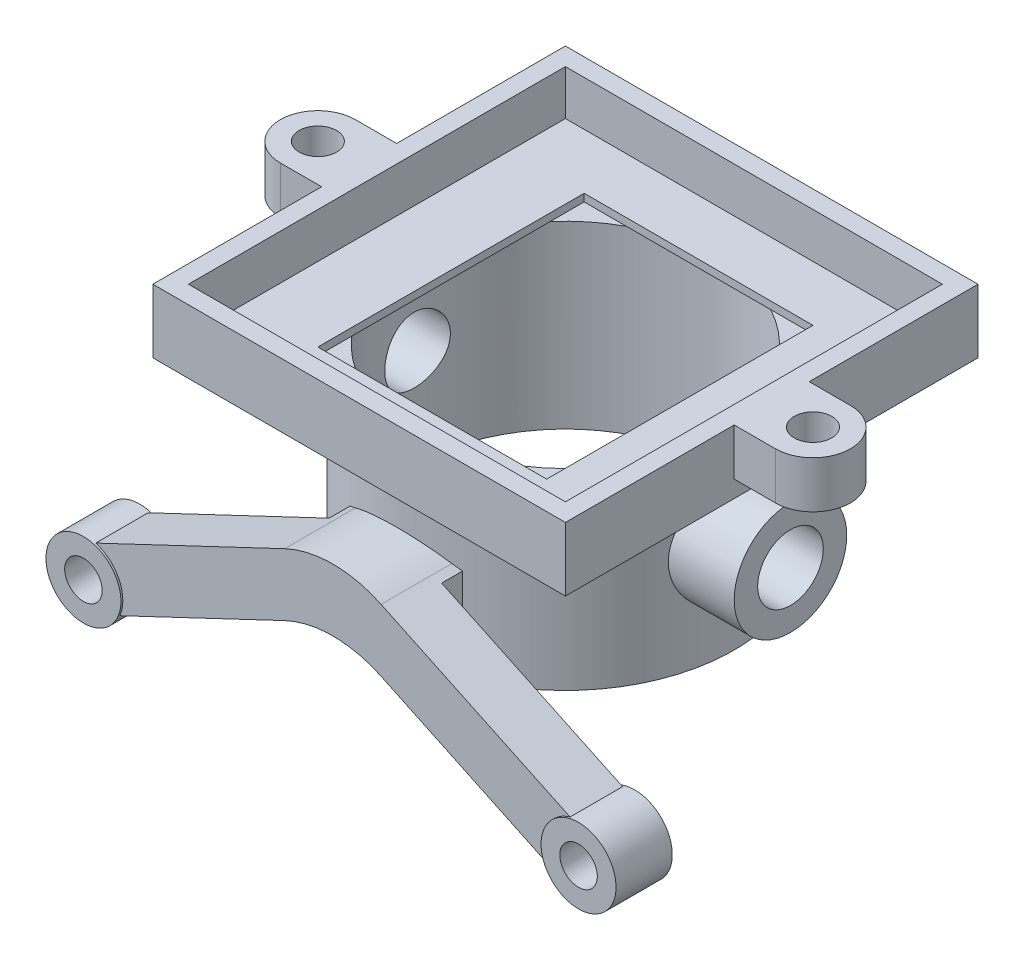
from build123d import *

# Parameters (mm, degrees)
SKETCH_1_R          = 4.5
SKETCH_1_R_2        = 4
EXTRUDE_1_DEPTH     = 4.5
SKETCH_2_W          = 11
SKETCH_2_H          = 11
SKETCH_2_R          = 4
EXTRUDE_2_DEPTH     = 0.5
SKETCH_3_W          = 6.1
SKETCH_3_H          = 7.1
CUT_EXTRUDE_1_DEPTH = 0.2
SKETCH_4_W          = 11
SKETCH_4_H          = 11
SKETCH_4_W_2        = 10.05
SKETCH_4_H_2        = 10.05
EXTRUDE_3_DEPTH     = 1.2
SKETCH_5_R          = 0.5
EXTRUDE_4_DEPTH     = 1.25
SKETCH_6_R          = 1
SKETCH_6_R_2        = 0.5
EXTRUDE_5_DEPTH     = 0.75
EXTRUDE_5_2_DEPTH   = 0.75
EXTRUDE_6_DEPTH     = 0.7
FILLET_1_R          = 3
EXTRUDE_7_DEPTH     = 0.9
EXTRUDE_8_DEPTH     = 0.2
SKETCH_12_R         = 4.5
CUT_EXTRUDE_2_DEPTH = 0.001
SKETCH_13_R         = 4.0375
CUT_EXTRUDE_3_DEPTH = 4.799
SKETCH_20_R         = 1.5
EXTRUDE_10_DEPTH    = 1.8
SKETCH_21_R         = 0.875
CUT_EXTRUDE_5_DEPTH = 3


with BuildPart() as part:
    # 草图1 → 凸台-拉伸1 (new body)
    with BuildSketch(Plane(origin=(0, 0, 0), x_dir=(1, 0, 0), z_dir=(0, 1, 0))):
        with Locations(Location((0, 0, 0), (0, 0, 270))):
            Circle(SKETCH_1_R)
        with Locations(Location((0, 0, 0), (0, 0, 270))):
            Circle(SKETCH_1_R_2, mode=Mode.SUBTRACT)
    extrude(amount=EXTRUDE_1_DEPTH)

    # 草图2 → 凸台-拉伸2 (add)
    with BuildSketch(Plane(origin=(0, 4.5, 0), x_dir=(1, 0, 0), z_dir=(0, 1, 0))):
        Rectangle(SKETCH_2_W, SKETCH_2_H)
        with Locations(Location((0, 0, 0), (0, 0, 270))):
            Circle(SKETCH_2_R, mode=Mode.SUBTRACT)
    extrude(amount=EXTRUDE_2_DEPTH)

    # 草图3 → 切除-拉伸1 (cut)
    with BuildSketch(Plane(origin=(0, 5, 0), x_dir=(1, 0, 0), z_dir=(0, 1, 0))):
        Rectangle(SKETCH_3_W, SKETCH_3_H)
    extrude(amount=-CUT_EXTRUDE_1_DEPTH, mode=Mode.SUBTRACT)

    # 草图4 → 凸台-拉伸3 (add)
    with BuildSketch(Plane(origin=(0, 5, 0), x_dir=(1, 0, 0), z_dir=(0, 1, 0))):
        Rectangle(SKETCH_4_W, SKETCH_4_H)
        Rectangle(SKETCH_4_W_2, SKETCH_4_H_2, mode=Mode.SUBTRACT)
    extrude(amount=EXTRUDE_3_DEPTH)

    # 草图5 → 凸台-拉伸4 (add)
    with BuildSketch(Plane(origin=(0, 6.2, 0), x_dir=(1, 0, 0), z_dir=(0, 1, 0))):
        with BuildLine():
            Line((5.5, 1), (5.5, -1))
            Line((5.5, -1), (6.6, -1))
            ThreePointArc((6.6, -1), (7.6, 0), (6.6, 1))
            Line((6.6, 1), (5.5, 1))
        make_face()
        with Locations(Location((6.6, 0, 0), (0, 0, 270))):
            Circle(SKETCH_5_R, mode=Mode.SUBTRACT)
        with BuildLine():
            Line((-6.6, -1), (-5.5, -1))
            Line((-5.5, -1), (-5.5, 1))
            Line((-5.5, 1), (-6.6, 1))
            ThreePointArc((-6.6, 1), (-7.6, 0), (-6.6, -1))
        make_face()
        with Locations(Location((-6.6, 0, 0), (0, 0, 270))):
            Circle(SKETCH_5_R, mode=Mode.SUBTRACT)
    extrude(amount=-EXTRUDE_4_DEPTH)



with BuildPart() as body_2:
    # 草图6 → 凸台-拉伸5 (new, symmetric)
    with BuildSketch(Plane.XY.offset(5.5)):
        with Locations((-6.6, -0.8)):
            Circle(SKETCH_6_R)
        with Locations((-6.6, -0.8)):
            Circle(SKETCH_6_R_2, mode=Mode.SUBTRACT)
    extrude(amount=EXTRUDE_5_DEPTH, both=True)



with BuildPart() as body_3:
    # 草图6 → Extrude 5 2 (new, symmetric)
    with BuildSketch(Plane.XY.offset(5.5)):
        with Locations(Location((6.6, -0.8, 0), (0, 0, 180))):
            Circle(SKETCH_6_R)
        with Locations(Location((6.6, -0.8, 0), (0, 0, 180))):
            Circle(SKETCH_6_R_2, mode=Mode.SUBTRACT)
    extrude(amount=EXTRUDE_5_2_DEPTH, both=True)


with BuildPart() as body_2_1:
    add(body_2.part)

    add(body_3.part)  # 凸台-拉伸6 merges body 3
    # 草图7 → 凸台-拉伸6 (add, symmetric)
    with BuildSketch(Plane.XY.offset(5.5)):
        Polygon((-6.469610026, 0.091907201), (0, 3.160138746), (6.469610026, 0.091907201), (5.826851035, -1.263401207), (0, 1.5), (-5.826851035, -1.263401207), align=None)
    extrude(amount=EXTRUDE_6_DEPTH, both=True)

    # 圆角1
    fillet_1_edges = [body_2_1.edges().sort_by_distance(p)[0] for p in [
        (0, 1.5, 5.5),
        (0, 3.160138746, 5.5),
    ]]
    fillet(fillet_1_edges, radius=FILLET_1_R)


with BuildPart() as part_1:
    add(part.part)

    add(body_2_1.part)  # 凸台-拉伸7 merges body 2
    # 草图8 → 凸台-拉伸7 (add)
    with BuildSketch(Plane(origin=(0, 0, 4.8), x_dir=(-1, 0, 0), z_dir=(0, 0, -1))):
        with BuildLine():
            Line((1.5, 2.448759343), (1.5, 0.788620597))
            Line((1.5, 0.788620597), (1.285517981, 0.890339324))
            ThreePointArc((1.285517981, 0.890339324), (0, 1.179722509), (-1.285517981, 0.890339324))
            Line((-1.285517981, 0.890339324), (-1.5, 0.788620597))
            Line((-1.5, 0.788620597), (-1.5, 2.448759343))
            Line((-1.5, 2.448759343), (-1.285517981, 2.55047807))
            ThreePointArc((-1.285517981, 2.55047807), (0, 2.839861254), (1.285517981, 2.55047807))
            Line((1.285517981, 2.55047807), (1.5, 2.448759343))
        make_face()
    extrude(amount=EXTRUDE_7_DEPTH)

    # 草图11 → 凸台-拉伸8 (add)
    with BuildSketch(Plane(origin=(0, 5, 0), x_dir=(1, 0, 0), z_dir=(0, 1, 0))):
        with BuildLine():
            Line((-3.05, 2.587952859), (-3.05, -2.587952859))
            ThreePointArc((-3.05, -2.587952859), (-4, 0), (-3.05, 2.587952859))
        make_face()
        with BuildLine():
            Line((3.05, 2.587952859), (3.05, -2.587952859))
            ThreePointArc((3.05, -2.587952859), (4, 0), (3.05, 2.587952859))
        make_face()
        with BuildLine():
            Line((-1.843230859, 3.55), (1.843230859, 3.55))
            ThreePointArc((1.843230859, 3.55), (0, 4), (-1.843230859, 3.55))
        make_face()
        with BuildLine():
            Line((-1.843230859, -3.55), (1.843230859, -3.55))
            ThreePointArc((1.843230859, -3.55), (0, -4), (-1.843230859, -3.55))
        make_face()
    extrude(amount=-EXTRUDE_8_DEPTH)

    # 草图12 → 切除-拉伸2 (cut)
    with BuildSketch(Plane.XZ):
        with Locations(Location((0, 0, 0), (0, 0, 270))):
            Circle(SKETCH_12_R)
    extrude(amount=-CUT_EXTRUDE_2_DEPTH, mode=Mode.SUBTRACT)

    # 草图13 → 切除-拉伸3 (cut)
    with BuildSketch(Plane.XZ.offset(-0.001)):
        with Locations(Location((0, 0, 0), (0, 0, 270))):
            Circle(SKETCH_13_R)
    extrude(amount=-CUT_EXTRUDE_3_DEPTH, mode=Mode.SUBTRACT)

    # 草图20 → 凸台-拉伸10 (add)
    with BuildSketch(Plane.ZY.offset(6)):
        with Locations((0, 2.657828557)):
            Circle(SKETCH_20_R)
    extrude_10 = extrude(amount=-EXTRUDE_10_DEPTH)

    # 草图21 → 切除-拉伸5 (cut)
    with BuildSketch(Plane.ZY.offset(6)):
        with Locations((0, 2.657828557)):
            Circle(SKETCH_21_R)
    cut_extrude_5 = extrude(amount=-CUT_EXTRUDE_5_DEPTH, mode=Mode.SUBTRACT)

    # 镜向3: 凸台-拉伸10, 切除-拉伸5 across plane
    add(extrude_10.mirror(Plane(origin=(0, 0, 0), x_dir=(0, 0, 1), z_dir=(1, 0, 0))))
    add(cut_extrude_5.mirror(Plane(origin=(0, 0, 0), x_dir=(0, 0, 1), z_dir=(1, 0, 0))), mode=Mode.SUBTRACT)


solid = part_1.part
